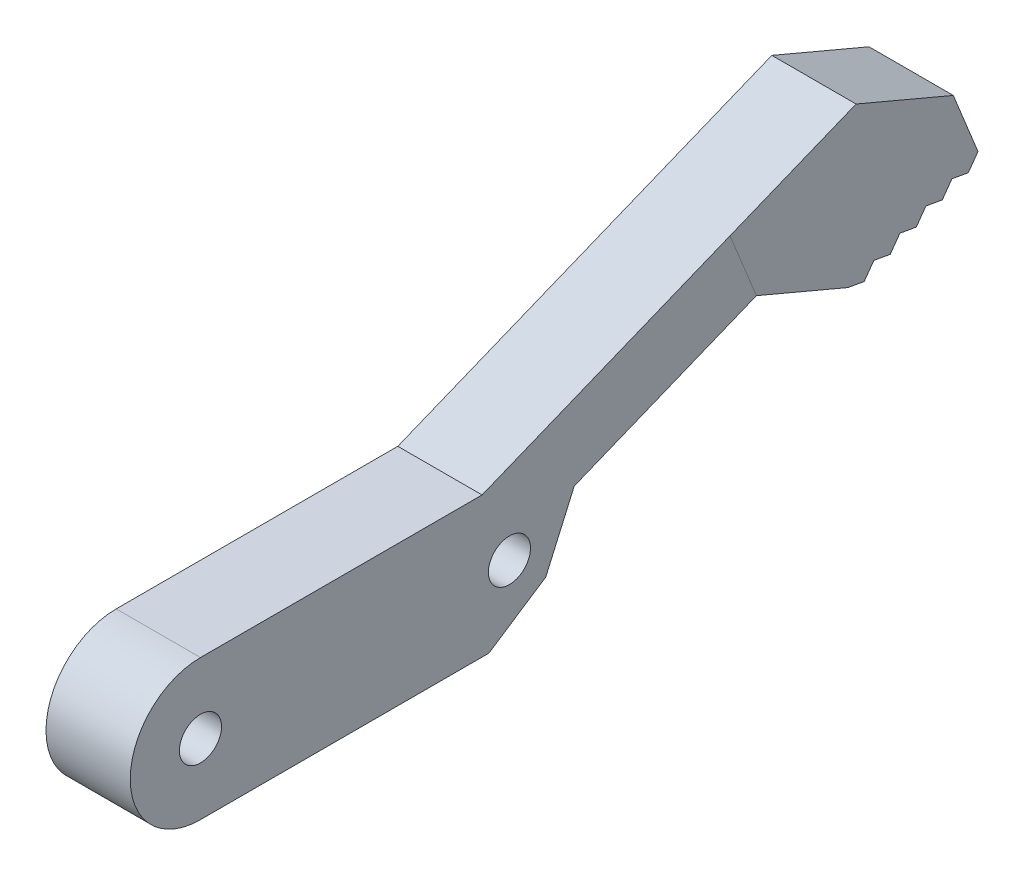
from build123d import *

# Parameters (mm, degrees)
SKETCH1_R           = 5
SKETCH1_R_2         = 1.5
BOSS_EXTRUDE1_DEPTH = 6
BOSS_EXTRUDE2_DEPTH = 6
CUT_EXTRUDE2_DEPTH  = 7
CUT_EXTRUDE3_DEPTH  = 10


with BuildPart() as part:
    # Sketch1 → Boss-Extrude1 (new body)
    with BuildSketch(Plane(origin=(0, 0, 0), x_dir=(0, 0, -1), z_dir=(1, 0, 0))):
        with Locations((5, 5)):
            Circle(SKETCH1_R)
        with Locations((5, 5)):
            Circle(SKETCH1_R_2, mode=Mode.SUBTRACT)
        with BuildLine():
            ThreePointArc((10, 5), (8.535533906, 1.464466094), (5, 0))
            Line((5, 0), (27, 0))
            ThreePointArc((27, 0), (22, 5), (27, 10))
            Line((27, 10), (5, 10))
            ThreePointArc((5, 10), (8.535533906, 8.535533906), (10, 5))
        make_face()
        with Locations((27, 5)):
            Circle(SKETCH1_R)
        with Locations((27, 5)):
            Circle(SKETCH1_R_2, mode=Mode.SUBTRACT)
    extrude(amount=BOSS_EXTRUDE1_DEPTH)

    # Sketch2 → Boss-Extrude2 (add)
    with BuildSketch(Plane(origin=(6, 0, 0), x_dir=(0, 0, -1), z_dir=(1, 0, 0))):
        with BuildLine():
            ThreePointArc((27, 10), (29.694507461, 9.21184396), (31.53953799, 7.095851816))
            Line((31.53953799, 7.095851816), (31.610157793, 7.262674791))
            Line((31.610157793, 7.262674791), (44.585599673, 12.519851602))
            Line((44.585599673, 12.519851602), (51.097249205, 9.763328363))
            Line((51.097249205, 9.763328363), (60.365421977, 13.518454657))
            Line((60.365421977, 13.518454657), (56.610295683, 22.786627428))
            Line((56.610295683, 22.786627428), (25.051124858, 10))
            Line((25.051124858, 10), (27, 10))
        make_face()
        Polygon((60.365421977, 13.518454657), (51.097249205, 9.763328363), (51.333822162, 9.179433479), (60.601994933, 12.934559772), align=None)
    extrude(amount=-BOSS_EXTRUDE2_DEPTH)

    # Sketch4 → Cut-Extrude2 (cut, through all)
    with BuildSketch(Plane(origin=(6, 0, 0), x_dir=(0, 0, -1), z_dir=(1, 0, 0))):
        Polygon((56.610295683, 22.786627428), (51.684261855, 20.790777803), (58.606145308, 17.8605936), align=None)
    extrude(amount=-CUT_EXTRUDE2_DEPTH, mode=Mode.SUBTRACT)

    # Sketch5 → Cut-Extrude3 (cut)
    with BuildSketch(Plane(origin=(6, 0, 0), x_dir=(0, 0, -1), z_dir=(1, 0, 0))):
        with BuildLine():
            ThreePointArc((27, 0), (31.21184396, 2.305492539), (31.53953799, 7.095851816))
            Line((31.53953799, 7.095851816), (29.583779735, 2.664986829))
            Line((29.583779735, 2.664986829), (25.539598719, 0))
            Line((25.539598719, 0), (27, 0))
        make_face()
        Polygon((52.260639439, 9.554946108), (51.097249205, 9.763328363), (51.333822162, 9.179433479), align=None)
        Polygon((52.95088376, 10.514353622), (52.260639439, 9.554946108), (54.114273993, 10.305971367), align=None)
        Polygon((54.804518314, 11.265378881), (54.114273993, 10.305971367), (55.967908548, 11.056996626), align=None)
        Polygon((56.658152868, 12.01640414), (55.967908548, 11.056996626), (57.821543102, 11.808021884), align=None)
        Polygon((58.511787422, 12.767429398), (57.821543102, 11.808021884), (59.675177656, 12.559047143), align=None)
        Polygon((60.365421977, 13.518454657), (59.675177656, 12.559047143), (60.601994933, 12.934559772), align=None)
    extrude(amount=-CUT_EXTRUDE3_DEPTH, mode=Mode.SUBTRACT)


solid = part.part
